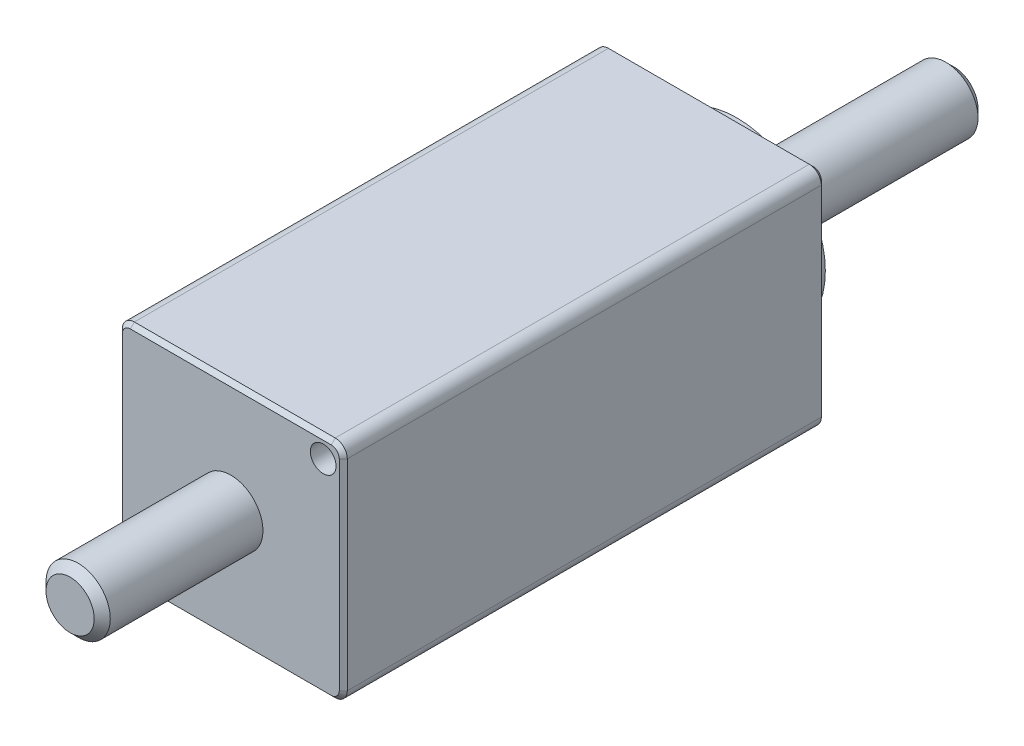
from build123d import *

# Parameters (mm, degrees)
SKETCH1_W                 = 14
SKETCH1_H                 = 14
BOSS_EXTRUDE1_DEPTH       = 30
SKETCH2_R                 = 5.5
BOSS_EXTRUDE2_DEPTH       = 1.5
SKETCH3_R                 = 2
BOSS_EXTRUDE4_DEPTH       = 13.5
SKETCH7_R                 = 2
BOSS_EXTRUDE6_DEPTH       = 10
CHAMFER1_SIZE             = 0.5
M2X0_4_TAPPED_HOLE1_D     = 1.6
M2X0_4_TAPPED_HOLE1_DEPTH = 4.4
M2X0_4_TAPPED_HOLE1_TIP   = 0.480688495
FILLET1_R                 = 0.75
CHAMFER2_SIZE             = 0.25
M2X0_4_TAPPED_HOLE2_D     = 1.6
M2X0_4_TAPPED_HOLE2_DEPTH = 4.4
M2X0_4_TAPPED_HOLE2_TIP   = 0.480688495


with BuildPart() as part:
    # Sketch1 → Boss-Extrude1 (new body)
    with BuildSketch(Plane.XY):
        Rectangle(SKETCH1_W, SKETCH1_H)
    extrude(amount=BOSS_EXTRUDE1_DEPTH)

    # Sketch2 → Boss-Extrude2 (add)
    with BuildSketch(Plane(origin=(0, 0, 0), x_dir=(-1, 0, 0), z_dir=(0, 0, -1))):
        Circle(SKETCH2_R)
    extrude(amount=BOSS_EXTRUDE2_DEPTH)

    # Sketch3 → Boss-Extrude4 (add)
    with BuildSketch(Plane(origin=(0, 0, -1.5), x_dir=(-1, 0, 0), z_dir=(0, 0, -1))):
        Circle(SKETCH3_R)
    extrude(amount=BOSS_EXTRUDE4_DEPTH)

    # Sketch7 → Boss-Extrude6 (add)
    with BuildSketch(Plane.XY.offset(30)):
        Circle(SKETCH7_R)
    extrude(amount=BOSS_EXTRUDE6_DEPTH)

    # Chamfer1
    chamfer1_edges = [part.edges().sort_by_distance(p)[0] for p in [
        (2, 0, -15),
        (-2, 0, 40),
    ]]
    chamfer(chamfer1_edges, length=CHAMFER1_SIZE)

    # M2x0.4 Tapped Hole1
    with Locations(Plane(origin=(0, 0, 0), x_dir=(-1, 0, 0), z_dir=(0, 0, -1))):
        with Locations((5.75, 5.75), (-5.75, 5.75), (-5.75, -5.75), (5.75, -5.75)):
            Hole(M2X0_4_TAPPED_HOLE1_D / 2, depth=M2X0_4_TAPPED_HOLE1_DEPTH)
            with Locations((0, 0, -(M2X0_4_TAPPED_HOLE1_DEPTH + M2X0_4_TAPPED_HOLE1_TIP / 2))):  # 118° drill point
                Cone(0, M2X0_4_TAPPED_HOLE1_D / 2, M2X0_4_TAPPED_HOLE1_TIP, mode=Mode.SUBTRACT)

    # Fillet1
    fillet1_edges = [part.edges().sort_by_distance(p)[0] for p in [
        (7, -7, 15),
        (-7, -7, 15),
        (-7, 7, 15),
        (7, 7, 15),
    ]]
    fillet(fillet1_edges, radius=FILLET1_R)

    # Chamfer2
    chamfer2_edges = [part.edges().sort_by_distance(p)[0] for p in [
        (0, 7, 0),
        (0, 7, 30),
        (7, 0, 0),
        (0, -7, 0),
        (-7, 0, 0),
        (-6.780330086, 6.780330086, 0),
        (-6.780330086, -6.780330086, 0),
        (6.780330086, -6.780330086, 0),
        (6.780330086, 6.780330086, 0),
        (7, 0, 30),
        (-7, 0, 30),
        (0, -7, 30),
        (-6.780330086, 6.780330086, 30),
        (-6.780330086, -6.780330086, 30),
        (6.780330086, -6.780330086, 30),
        (6.780330086, 6.780330086, 30),
    ]]
    chamfer(chamfer2_edges, length=CHAMFER2_SIZE)

    # M2x0.4 Tapped Hole2
    with Locations(Plane.XY.offset(30)):
        with Locations((5.75, 5.75), (-5.75, -5.75)):
            Hole(M2X0_4_TAPPED_HOLE2_D / 2, depth=M2X0_4_TAPPED_HOLE2_DEPTH)
            with Locations((0, 0, -(M2X0_4_TAPPED_HOLE2_DEPTH + M2X0_4_TAPPED_HOLE2_TIP / 2))):  # 118° drill point
                Cone(0, M2X0_4_TAPPED_HOLE2_D / 2, M2X0_4_TAPPED_HOLE2_TIP, mode=Mode.SUBTRACT)


solid = part.part
